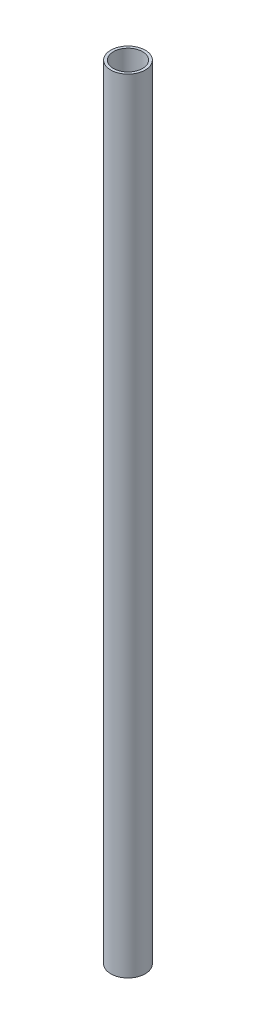
from build123d import *

# Parameters (mm, degrees)
SKETCH_1_R          = 13
SKETCH_1_R_2        = 11
EXTRUDE_1_DEPTH     = 590
SKETCH_2_R          = 2.5
CUT_EXTRUDE_1_DEPTH = 14


with BuildPart() as part:
    # 草图1 → 凸台-拉伸1 (new body)
    with BuildSketch(Plane(origin=(0, 0, 0), x_dir=(1, 0, 0), z_dir=(0, 1, 0))):
        Circle(SKETCH_1_R)
        Circle(SKETCH_1_R_2, mode=Mode.SUBTRACT)
    extrude(amount=EXTRUDE_1_DEPTH)

    # 草图2 → 切除-拉伸1 (cut, through all)
    with BuildSketch(Plane(origin=(0, 0, 0), x_dir=(0, 0, -1), z_dir=(1, 0, 0))):
        with Locations((0, 22.5)):
            Circle(SKETCH_2_R)
        with Locations((0, 571.5)):
            Circle(SKETCH_2_R)
    extrude(amount=-CUT_EXTRUDE_1_DEPTH, mode=Mode.SUBTRACT)


solid = part.part
